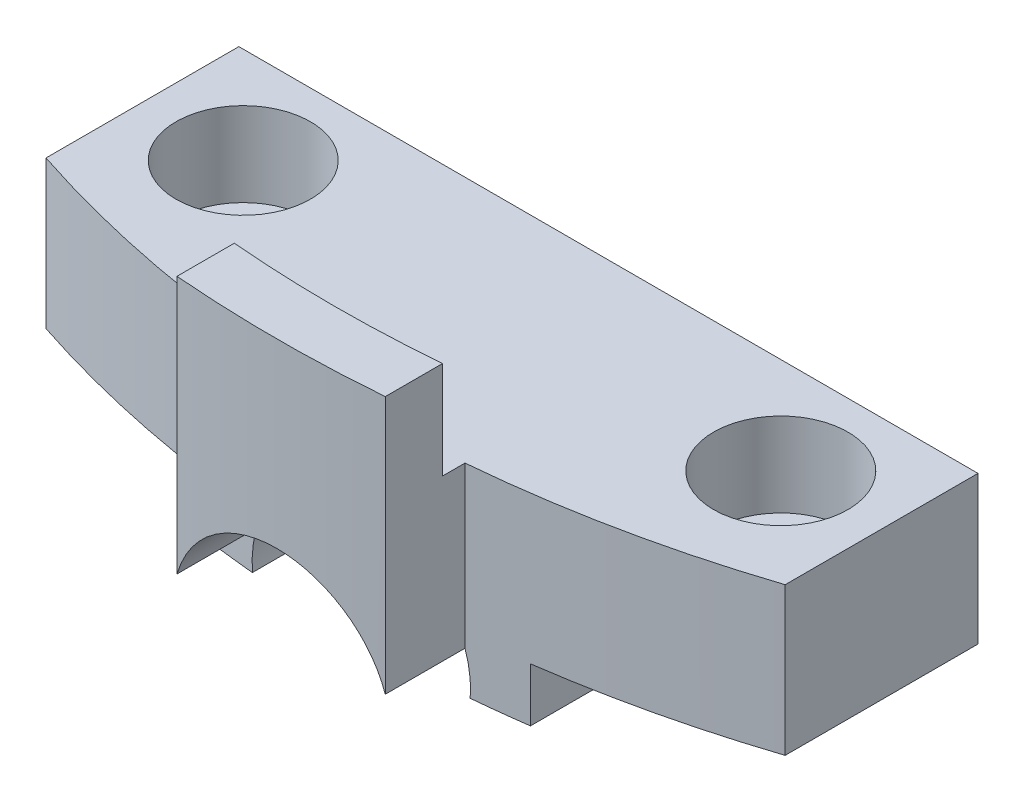
from build123d import *

# Parameters (mm, degrees)
SKETCH1_R           = 1.1
BOSS_EXTRUDE1_DEPTH = 4.4
BOSS_EXTRUDE2_DEPTH = 2.9
SKETCH3_R           = 2
CUT_EXTRUDE1_DEPTH  = 2.5
BOSS_EXTRUDE3_DEPTH = 1.6
SKETCH6_R           = 3.25
CUT_EXTRUDE2_DEPTH  = 10.869724242


with BuildPart() as part:
    # Sketch1 → Boss-Extrude1 (new body)
    with BuildSketch(Plane(origin=(0, 0, 0), x_dir=(1, 0, 0), z_dir=(0, 1, 0))):
        with BuildLine():
            Line((-3.1, -37.371647007), (-3.1, -34.998978499))
            ThreePointArc((-3.1, -34.998978499), (-7.096909, -34.411805803), (-11, -33.369724242))
            Line((-11, -33.369724242), (-11, -27.630275758))
            Line((-11, -27.630275758), (11, -27.630275758))
            Line((11, -27.630275758), (11, -33.369724242))
            ThreePointArc((11, -33.369724242), (7.096909, -34.411805803), (3.1, -34.998978499))
            Line((3.1, -34.998978499), (3.1, -37.371647007))
            ThreePointArc((3.1, -37.371647007), (0, -37.5), (-3.1, -37.371647007))
        make_face()
        with Locations((-8, -30.5)):
            Circle(SKETCH1_R, mode=Mode.SUBTRACT)
        with Locations((8, -30.5)):
            Circle(SKETCH1_R, mode=Mode.SUBTRACT)
    extrude(amount=BOSS_EXTRUDE1_DEPTH)

    # Sketch2 → Boss-Extrude2 (add)
    with BuildSketch(Plane(origin=(0, 4.4, 0), x_dir=(1, 0, 0), z_dir=(0, 1, 0))):
        with BuildLine():
            Line((3.1, -37.371647007), (3.1, -35.665529577))
            ThreePointArc((3.1, -35.665529577), (0, -35.8), (-3.1, -35.665529577))
            Line((-3.1, -35.665529577), (-3.1, -37.371647007))
            ThreePointArc((-3.1, -37.371647007), (0, -37.5), (3.1, -37.371647007))
        make_face()
    extrude(amount=BOSS_EXTRUDE2_DEPTH)

    # Sketch3 → Cut-Extrude1 (cut)
    with BuildSketch(Plane(origin=(0, 4.4, 0), x_dir=(1, 0, 0), z_dir=(0, 1, 0))):
        with Locations((-8, -30.5)):
            Circle(SKETCH3_R)
        with Locations((8, -30.5)):
            Circle(SKETCH3_R)
    extrude(amount=-CUT_EXTRUDE1_DEPTH, mode=Mode.SUBTRACT)

    # Sketch5 → Boss-Extrude3 (add)
    with BuildSketch(Plane.XZ):
        with BuildLine():
            Line((-4.85, 34.799655113), (-4.85, 27.630275758))
            Line((-4.85, 27.630275758), (4.85, 27.630275758))
            Line((4.85, 27.630275758), (4.85, 34.799655113))
            ThreePointArc((4.85, 34.799655113), (3.976249169, 34.910284137), (3.1, 34.998978499))
            Line((3.1, 34.998978499), (3.1, 37.371647007))
            ThreePointArc((3.1, 37.371647007), (0, 37.5), (-3.1, 37.371647007))
            Line((-3.1, 37.371647007), (-3.1, 34.998978499))
            ThreePointArc((-3.1, 34.998978499), (-3.976249169, 34.910284137), (-4.85, 34.799655113))
        make_face()
    extrude(amount=BOSS_EXTRUDE3_DEPTH)

    # Sketch6 → Cut-Extrude2 (cut, through all)
    with BuildSketch(Plane(origin=(0, 0, 27.630275758), x_dir=(-1, 0, 0), z_dir=(0, 0, -1))):
        with Locations((0, -1.35)):
            Circle(SKETCH6_R)
    extrude(amount=-CUT_EXTRUDE2_DEPTH, mode=Mode.SUBTRACT)


solid = part.part
